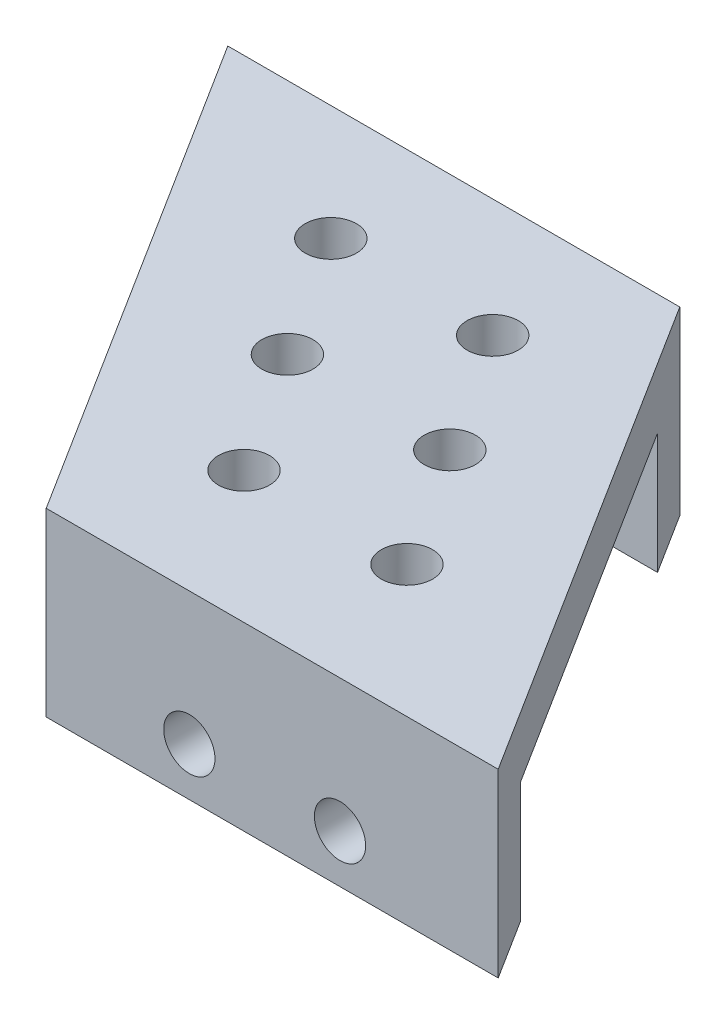
from build123d import *

# Parameters (mm, degrees)
ESTRUSIONE_ESTRUSIONE1_DEPTH = 4
ESTRUSIONE_ESTRUSIONE2_DEPTH = 8
SCHIZZO7_R                   = 1.7
TAGLIO_ESTRUSIONE4_DEPTH     = 13
SCHIZZO10_R                  = 1.7
TAGLIO_ESTRUSIONE5_DEPTH     = 10
SCHIZZO11_R                  = 1.7
TAGLIO_ESTRUSIONE6_DEPTH     = 10


with BuildPart() as part:
    # Schizzo1 → Estrusione-Estrusione1 (new body)
    with BuildSketch(Plane(origin=(0, 0, 0), x_dir=(1, 0, 0), z_dir=(0, 1, 0))):
        Polygon((1.585961517, 7.064649843), (22.133260635, -25.535350157), (-7.866739365, -25.535350157), (-28.414038483, 7.064649843), align=None)
    extrude(amount=ESTRUSIONE_ESTRUSIONE1_DEPTH)

    # Schizzo4 → Estrusione-Estrusione2 (add)
    with BuildSketch(Plane.XZ):
        Polygon((-28.414038483, -7.064649843), (-25.892897487, -3.064649843), (4.107102513, -3.064649843), (1.585961517, -7.064649843), align=None)
        Polygon((22.133260635, 25.535350157), (-7.866739365, 25.535350157), (-10.387880361, 21.535350157), (19.612119639, 21.535350157), align=None)
    extrude(amount=ESTRUSIONE_ESTRUSIONE2_DEPTH)

    # Schizzo7 → Taglio-Estrusione4 (cut, through all)
    with BuildSketch(Plane(origin=(0, 4, 0), x_dir=(1, 0, 0), z_dir=(0, 1, 0))):
        with Locations((7.329259334, -16.787762722)):
            Circle(SCHIZZO7_R)
        with Locations((-3.487605714, -16.787762722)):
            Circle(SCHIZZO7_R)
        with Locations((-8.711706468, -8.681963492)):
            Circle(SCHIZZO7_R)
        with Locations((-13.935807222, -0.576164263)):
            Circle(SCHIZZO7_R)
        with Locations((-2.9886387, -0.77834524)):
            Circle(SCHIZZO7_R)
        with Locations((2.170310317, -8.783053981)):
            Circle(SCHIZZO7_R)
    extrude(amount=-TAGLIO_ESTRUSIONE4_DEPTH, mode=Mode.SUBTRACT)

    # Schizzo10 → Taglio-Estrusione5 (cut)
    with BuildSketch(Plane.XY.offset(25.535350157)):
        with Locations((1.633260635, -4.8)):
            Circle(SCHIZZO10_R)
        with Locations((11.633260635, -4.8)):
            Circle(SCHIZZO10_R)
    extrude(amount=-TAGLIO_ESTRUSIONE5_DEPTH, mode=Mode.SUBTRACT)

    # Schizzo11 → Taglio-Estrusione6 (cut)
    with BuildSketch(Plane(origin=(0, 0, -7.064649843), x_dir=(-1, 0, 0), z_dir=(0, 0, -1))):
        with Locations((9.414038483, -4.8)):
            Circle(SCHIZZO11_R)
        with Locations((19.414038483, -4.8)):
            Circle(SCHIZZO11_R)
    extrude(amount=-TAGLIO_ESTRUSIONE6_DEPTH, mode=Mode.SUBTRACT)


solid = part.part
